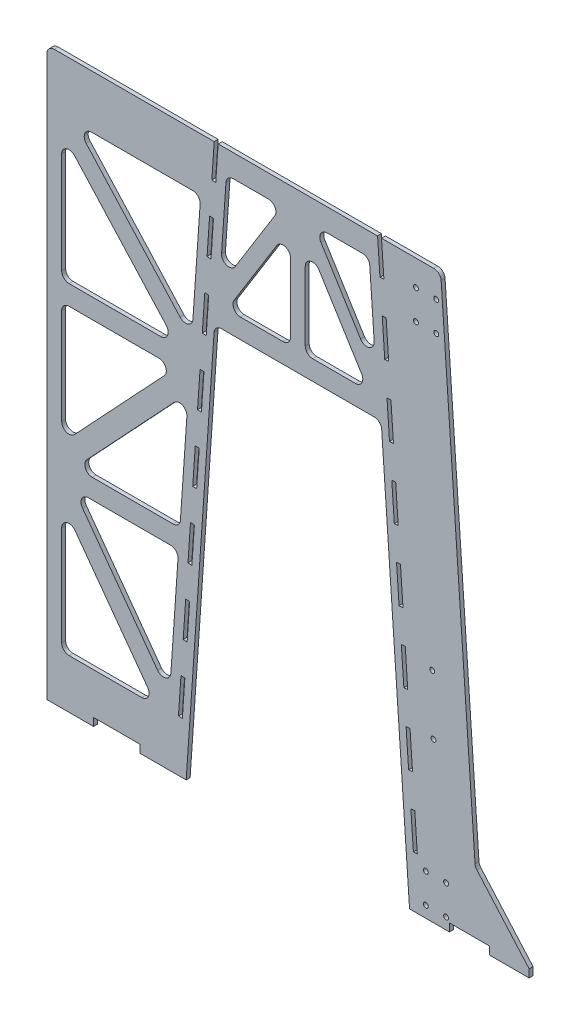
from build123d import *

# Parameters (mm, degrees)
BOSS_EXTRUDE1_DEPTH = 10.16
FILLET1_R           = 19.05
SKETCH2_W           = 120.284747719
SKETCH2_H           = 20.32
SKETCH2_W_2         = 102.891608588
CUT_EXTRUDE1_DEPTH  = 12.7
SKETCH6_R           = 6.35
CUT_EXTRUDE2_DEPTH  = 10.16


with BuildPart() as part:
    # Sketch1 → Boss-Extrude1 (new body)
    with BuildSketch(Plane.XY):
        Polygon((-288.275887252, 0), (-215.032557346, 1054.1), (215.032557346, 1054.1), (288.275887252, 0), (596.950713016, 0), (596.950713016, 20.32), (457.769290722, 178.8375841), (368.537470958, 1463.04), (215.892500906, 1463.04), (-205.715298803, 1463.040000035), (-647.718210796, 1463.04), (-647.718210796, 0), align=None)
        Polygon((-609.618210796, 127), (-609.618210796, 461.510956689), (-365.626284392, 127), align=None, mode=Mode.SUBTRACT)
        Polygon((-609.618210796, 592.582701044), (-609.618210796, 907.626666667), (-314.736774564, 907.626666667), align=None, mode=Mode.SUBTRACT)
        Polygon((-282.735998162, 867.476761947), (-304.419486117, 555.413333333), (-574.827649063, 555.413333333), align=None, mode=Mode.SUBTRACT)
        Polygon((-307.949285149, 504.613333333), (-331.453012037, 166.353473425), (-578.179384354, 504.613333333), align=None, mode=Mode.SUBTRACT)
        Polygon((-609.618210796, 958.426666667), (-609.618210796, 1288.067621407), (-310.704175954, 958.426666667), align=None, mode=Mode.SUBTRACT)
        Polygon((-575.330448642, 1325.88), (-250.884200804, 1325.88), (-273.976047339, 993.547820907), align=None, mode=Mode.SUBTRACT)
        Polygon((19.05, 1104.9), (19.05, 1368.504716774), (182.716004616, 1104.9), align=None, mode=Mode.SUBTRACT)
        Polygon((41.473134849, 1404.62), (184.313325179, 1404.62), (202.313466912, 1145.566384812), align=None, mode=Mode.SUBTRACT)
        Polygon((-184.313325179, 1404.62), (-41.473134849, 1404.62), (-202.313466912, 1145.566384812), align=None, mode=Mode.SUBTRACT)
        Polygon((-19.05, 1368.504716774), (-19.05, 1104.9), (-182.716004616, 1104.9), align=None, mode=Mode.SUBTRACT)
    extrude(amount=BOSS_EXTRUDE1_DEPTH)

    # Fillet1
    fillet1_edges = [part.edges().sort_by_distance(p)[0] for p in [
        (19.05, 1368.504716774, 5.08),
        (19.05, 1104.9, 5.08),
        (182.716004616, 1104.9, 5.08),
        (-250.884200804, 1325.88, 5.08),
        (-575.330448642, 1325.88, 5.08),
        (-273.976047339, 993.547820907, 5.08),
        (-647.718210796, 1463.04, 5.08),
        (368.537470958, 1463.04, 5.08),
        (457.769290722, 178.8375841, 5.08),
        (215.032557346, 1054.1, 5.08),
        (-215.032557346, 1054.1, 5.08),
        (-609.618210796, 1288.067621407, 5.08),
        (-609.618210796, 958.426666667, 5.08),
        (-310.704175954, 958.426666667, 5.08),
        (-609.618210796, 461.510956689, 5.08),
        (-609.618210796, 127, 5.08),
        (-365.626284392, 127, 5.08),
        (-41.473134849, 1404.62, 5.08),
        (-184.313325179, 1404.62, 5.08),
        (-202.313466912, 1145.566384812, 5.08),
        (-182.716004616, 1104.9, 5.08),
        (-19.05, 1104.9, 5.08),
        (-19.05, 1368.504716774, 5.08),
        (184.313325179, 1404.62, 5.08),
        (41.473134849, 1404.62, 5.08),
        (202.313466912, 1145.566384812, 5.08),
        (-578.179384354, 504.613333333, 5.08),
        (-331.453012037, 166.353473425, 5.08),
        (-307.949285149, 504.613333333, 5.08),
        (-609.618210796, 907.626666667, 5.08),
        (-609.618210796, 592.582701044, 5.08),
        (-314.736774564, 907.626666667, 5.08),
        (-574.827649063, 555.413333333, 5.08),
        (-304.419486117, 555.413333333, 5.08),
        (-282.735998162, 867.476761947, 5.08),
    ]]
    fillet(fillet1_edges, radius=FILLET1_R)

    # Sketch2 → Cut-Extrude1 (cut)
    with BuildSketch(Plane.XY.offset(10.16)):
        with Locations((-467.291089218, 10.16)):
            Rectangle(SKETCH2_W, SKETCH2_H)
        with Locations((442.613300134, 10.16)):
            Rectangle(SKETCH2_W_2, SKETCH2_H)
        Polygon((211.92306481, 1373.664189215), (222.040744894, 1374.366931824), (215.881789204, 1463.040000035), (205.715298803, 1463.040000035), align=None)
        Polygon((234.358656272, 1197.020795404), (227.836927701, 1290.916856945), (217.719247617, 1290.214114336), (224.240976188, 1196.318052795), align=None)
        Polygon((246.676567651, 1019.674658983), (240.15668194, 1113.544188093), (230.039001856, 1112.841445484), (236.558887567, 1018.971916374), align=None)
        Polygon((258.99447903, 842.328522563), (252.476436179, 936.171519242), (242.358756095, 935.468776633), (248.876798945, 841.625779953), align=None)
        Polygon((271.312390408, 664.982386142), (264.796190418, 758.798850391), (254.678510334, 758.096107781), (261.194710324, 664.279643533), align=None)
        Polygon((283.630301787, 487.636249721), (277.115944656, 581.426181539), (266.998264572, 580.72343893), (273.512621703, 486.933507112), align=None)
        Polygon((295.948213166, 310.290113301), (289.435698895, 404.053512688), (279.318018811, 403.350770078), (285.830533081, 309.587370692), align=None)
        Polygon((308.266124544, 132.94397688), (301.755453134, 226.680843836), (291.63777305, 225.978101227), (298.14844446, 132.241234271), align=None)
        Polygon((-301.755453134, 226.680843836), (-308.266124544, 132.94397688), (-298.14844446, 132.241234271), (-291.63777305, 225.978101227), align=None)
        Polygon((-289.435698895, 404.053512688), (-295.948213166, 310.290113301), (-285.830533081, 309.587370692), (-279.318018811, 403.350770078), align=None)
        Polygon((-277.115944656, 581.426181539), (-283.630301787, 487.636249721), (-273.512621703, 486.933507112), (-266.998264572, 580.72343893), align=None)
        Polygon((-264.796190418, 758.798850391), (-271.312390408, 664.982386142), (-261.194710324, 664.279643533), (-254.678510334, 758.096107781), align=None)
        Polygon((-252.476436179, 936.171519242), (-258.99447903, 842.328522563), (-248.876798945, 841.625779953), (-242.358756095, 935.468776633), align=None)
        Polygon((-240.15668194, 1113.544188093), (-246.676567651, 1019.674658983), (-236.558887567, 1018.971916374), (-230.039001856, 1112.841445484), align=None)
        Polygon((-227.836927701, 1290.916856945), (-234.358656272, 1197.020795404), (-224.240976188, 1196.318052795), (-217.719247617, 1290.214114336), align=None)
        Polygon((-222.040744894, 1374.366931824), (-211.92306481, 1373.664189215), (-205.715298803, 1463.040000035), (-215.881789204, 1463.040000035), align=None)
    extrude(amount=-CUT_EXTRUDE1_DEPTH, mode=Mode.SUBTRACT)

    # Sketch6 → Cut-Extrude2 (cut)
    with BuildSketch(Plane.XY.offset(10.16)):
        with Locations((357.1875, 1397)):
            Circle(SKETCH6_R)
        with Locations((357.1875, 1320.8)):
            Circle(SKETCH6_R)
        with Locations((304.8, 1320.8)):
            Circle(SKETCH6_R)
        with Locations((304.8, 1397)):
            Circle(SKETCH6_R)
        with Locations((382.5875, 105.41)):
            Circle(SKETCH6_R)
        with Locations((382.5875, 29.21)):
            Circle(SKETCH6_R)
        with Locations((330.2, 29.21)):
            Circle(SKETCH6_R)
        with Locations((330.2, 105.41)):
            Circle(SKETCH6_R)
        with Locations((350.023844044, 410.21)):
            Circle(SKETCH6_R)
        with Locations((346.838891066, 562.61)):
            Circle(SKETCH6_R)
    extrude(amount=-CUT_EXTRUDE2_DEPTH, mode=Mode.SUBTRACT)


solid = part.part
